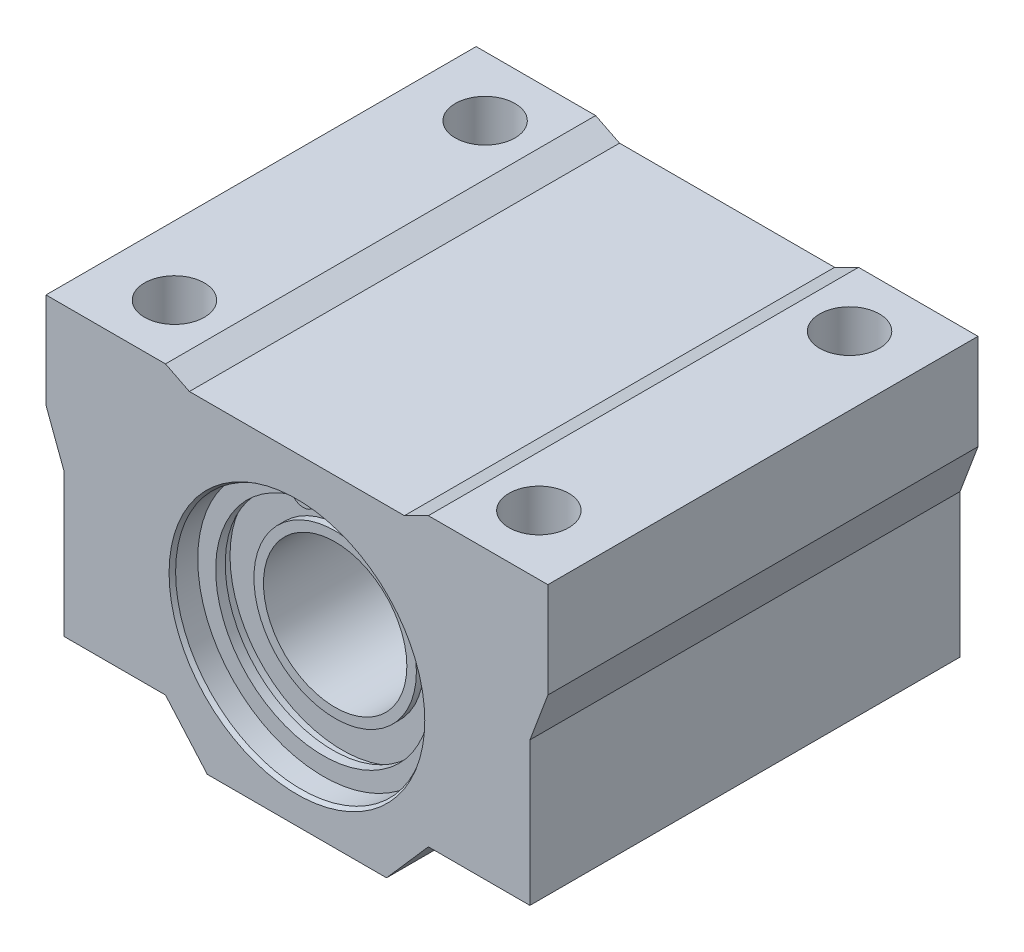
from build123d import *

# Parameters (mm, degrees)
SKETCH1_R                  = 10.5
BOSS_EXTRUDE1_DEPTH        = 18
SKETCH3_R                  = 0.487346303
BOSS_EXTRUDE2_DEPTH        = 0.8
M5_TAPPED_HOLE1_AT_2_COUNT = 2
M5_TAPPED_HOLE1_AT_2_PITCH = 26
M5_TAPPED_HOLE1_AT_3_COUNT = 2
M5_TAPPED_HOLE1_AT_3_PITCH = 30.5
M5_TAPPED_HOLE1_AT_4_COUNT = 2
M5_TAPPED_HOLE1_AT_4_PITCH = 40.078048855
CHAMFER1_SIZE              = 0.2
CHAMFER1_SIZE2             = 0.346410162
CHAMFER1_PART_2_SIZE       = 0.2
CHAMFER1_PART_2_SIZE2      = 0.346410162


with BuildPart() as part:
    # Sketch1 → Boss-Extrude1 (new body, symmetric)
    with BuildSketch(Plane.XY):
        Polygon((-9, -1), (9, -1), (11, 0), (21, 0), (21, -8), (19.5, -12), (19.5, -24), (11, -24), (7.5, -28), (-7.5, -28), (-11, -24), (-19.5, -24), (-19.5, -12), (-21, -8), (-21, 0), (-11, 0), align=None)
        with Locations((0, -15)):
            Circle(SKETCH1_R, mode=Mode.SUBTRACT)
    extrude(amount=BOSS_EXTRUDE1_DEPTH, both=True)

    # Sketch2 → Revolve1 (revolve)
    with BuildSketch(Plane(origin=(0, 0, 0), x_dir=(0, 0, -1), z_dir=(1, 0, 0))):
        Polygon((-15, -4.5), (15, -4.5), (15, -5.6), (14.2, -5.6), (14.2, -8.2), (14.8, -8.2), (14.8, -9), (-14.8, -9), (-14.8, -8.2), (-14.2, -8.2), (-14.2, -5.6), (-15, -5.6), align=None)
    revolve(axis=Axis((0, -15, 30.2753079), (0, 0, -1)))

    # Sketch3 → Boss-Extrude2 (add)
    with BuildSketch(Plane.XY.offset(15)):
        with BuildLine():
            Line((1.141194716, -4.059356755), (0.643070986, -5.356749026))
            ThreePointArc((0.643070986, -5.356749026), (1.151535438, -6.713388037), (2.559436926, -6.371600228))
            ThreePointArc((2.559436926, -6.371600228), (0, -24), (-2.559436926, -6.371600228))
            ThreePointArc((-2.559436926, -6.371600228), (-1.151535438, -6.713388037), (-0.643070986, -5.356749026))
            Line((-0.643070986, -5.356749026), (-1.141194716, -4.059356755))
            ThreePointArc((-1.141194716, -4.059356755), (0, -26), (1.141194716, -4.059356755))
        make_face()
        with Locations((1.662663475, -5.748213677)):
            Circle(SKETCH3_R, mode=Mode.SUBTRACT)
        with Locations((-1.662663475, -5.748213677)):
            Circle(SKETCH3_R, mode=Mode.SUBTRACT)
    boss_extrude2 = extrude(amount=BOSS_EXTRUDE2_DEPTH)

    # Mirror1: Boss-Extrude2 across plane
    add(boss_extrude2.mirror(Plane.XY))

    # Sketch6 → M5 Tapped Hole1 (revolve, cut)
    with BuildSketch(Plane(origin=(15.25, 0, -13), x_dir=(0, 0, 1), z_dir=(1, 0, 0))):
        Polygon((0, 0), (0, 24), (2.5, 24), (2.1, 23.6), (2.1, 12), (2.5, 12), (2.5, 0), align=None)
    m5_tapped_hole1 = revolve(axis=Axis((15.25, 6.35, -13), (0, -1, 0)), mode=Mode.SUBTRACT)

    # M5 Tapped Hole1 at 2: M5 Tapped Hole1 ×2
    with Locations(*[(0, 0, i * M5_TAPPED_HOLE1_AT_2_PITCH) for i in range(1, M5_TAPPED_HOLE1_AT_2_COUNT)]):
        add(m5_tapped_hole1, mode=Mode.SUBTRACT)

    # M5 Tapped Hole1 at 3: M5 Tapped Hole1 ×2
    with Locations(*[(-i * M5_TAPPED_HOLE1_AT_3_PITCH, 0, 0) for i in range(1, M5_TAPPED_HOLE1_AT_3_COUNT)]):
        add(m5_tapped_hole1, mode=Mode.SUBTRACT)

    # M5 Tapped Hole1 at 4: M5 Tapped Hole1 ×2
    with Locations(*[Vector(-0.761015091, 0, 0.648734176) * (i * M5_TAPPED_HOLE1_AT_4_PITCH) for i in range(1, M5_TAPPED_HOLE1_AT_4_COUNT)]):
        add(m5_tapped_hole1, mode=Mode.SUBTRACT)

    # Chamfer1
    chamfer1_edges = [part.edges().sort_by_distance(p)[0] for p in [
        (-10.5, -15, -18),
    ]]
    chamfer1_side = [part.faces().sort_by_distance(p)[0] for p in [
        (-10.5, -15, -16.5),
    ]]
    chamfer(chamfer1_edges, length=CHAMFER1_SIZE, length2=CHAMFER1_SIZE2, reference=chamfer1_side[0])

    # Chamfer1 part 2
    chamfer1_part_2_edges = [part.edges().sort_by_distance(p)[0] for p in [
        (-10.5, -15, 18),
    ]]
    chamfer1_part_2_side = [part.faces().sort_by_distance(p)[0] for p in [
        (0, -1.504777179, 18),
    ]]
    chamfer(chamfer1_part_2_edges, length=CHAMFER1_PART_2_SIZE, length2=CHAMFER1_PART_2_SIZE2, reference=chamfer1_part_2_side[0])


solid = part.part
